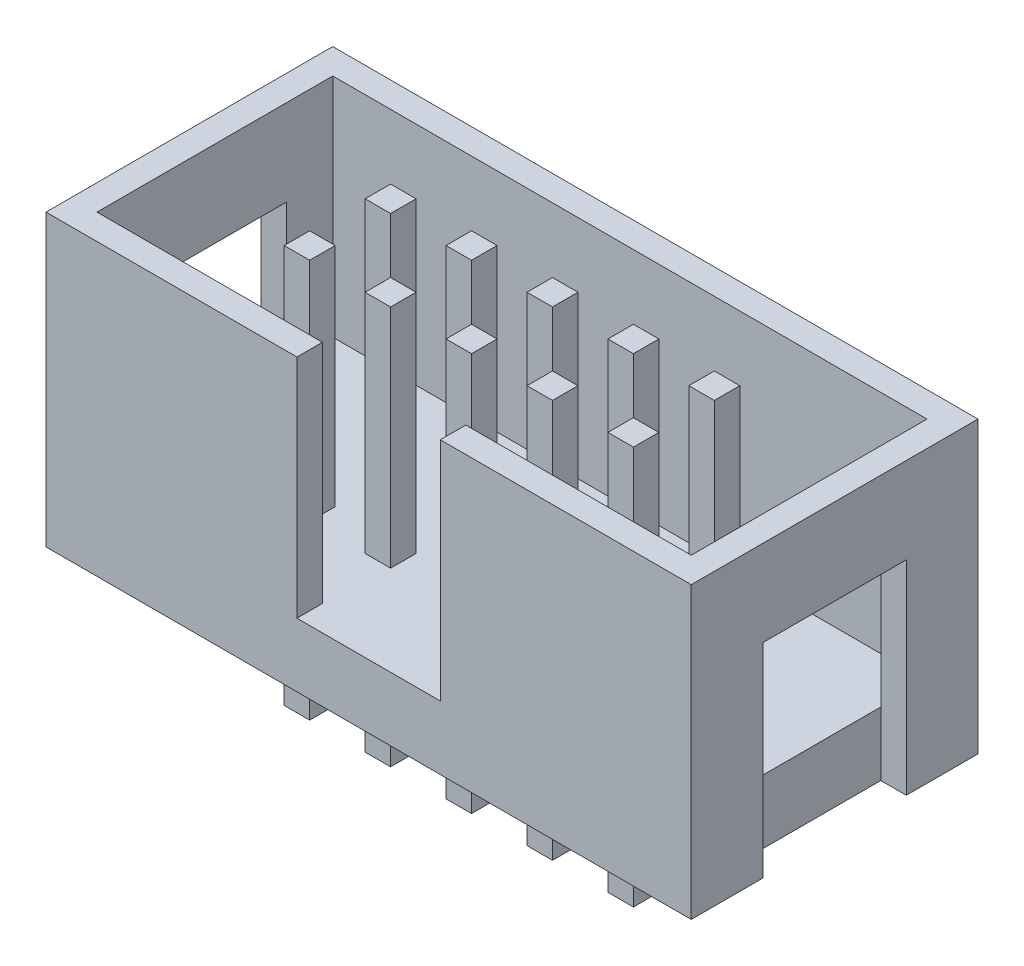
from build123d import *

# Parameters (mm, degrees)
SKETCH1_W           = 20.25
SKETCH1_H           = 9
BOSS_EXTRUDE1_DEPTH = 9.1
SKETCH2_W           = 18.65
SKETCH2_H           = 7.4
CUT_EXTRUDE1_DEPTH  = 7.1
SKETCH2_3_W         = 0.8
SKETCH2_3_H         = 0.8
BOSS_EXTRUDE2_DEPTH = 12.5
SKETCH3_W           = 4.5
SKETCH3_H           = 7.1
CUT_EXTRUDE2_DEPTH  = 2.1
SKETCH5_W           = 4.5
SKETCH5_H           = 6.4
CUT_EXTRUDE3_DEPTH  = 0.8
SKETCH6_W           = 4.5
SKETCH6_H           = 6.4
CUT_EXTRUDE4_DEPTH  = 0.8


with BuildPart() as part:
    # Sketch1 → Boss-Extrude1 (new body)
    with BuildSketch(Plane(origin=(0, 0, 0), x_dir=(1, 0, 0), z_dir=(0, 1, 0))):
        with Locations((-29.615572658, 24.590099186)):
            Rectangle(SKETCH1_W, SKETCH1_H)
    extrude(amount=BOSS_EXTRUDE1_DEPTH)

    # Sketch2 → Cut-Extrude1 (cut)
    with BuildSketch(Plane(origin=(0, 9.1, 0), x_dir=(1, 0, 0), z_dir=(0, 1, 0))):
        with Locations((-29.615572658, 24.590099186)):
            Rectangle(SKETCH2_W, SKETCH2_H)
    extrude(amount=-CUT_EXTRUDE1_DEPTH, mode=Mode.SUBTRACT)

    # Sketch2_3 → Boss-Extrude2 (add)
    with BuildSketch(Plane(origin=(0, 9.1, 0), x_dir=(1, 0, 0), z_dir=(0, 1, 0))):
        with Locations((-32.155572658, 23.320099186)):
            Rectangle(SKETCH2_3_W, SKETCH2_3_H)
        with Locations((-29.615572658, 23.320099186)):
            Rectangle(SKETCH2_3_W, SKETCH2_3_H)
        with Locations((-27.075572658, 23.320099186)):
            Rectangle(SKETCH2_3_W, SKETCH2_3_H)
        with Locations((-24.535572658, 23.320099186)):
            Rectangle(SKETCH2_3_W, SKETCH2_3_H)
        with Locations((-29.615572658, 25.860099186)):
            Rectangle(SKETCH2_3_W, SKETCH2_3_H)
        with Locations((-27.075572658, 25.860099186)):
            Rectangle(SKETCH2_3_W, SKETCH2_3_H)
        with Locations((-24.535572658, 25.860099186)):
            Rectangle(SKETCH2_3_W, SKETCH2_3_H)
        with Locations((-32.155572658, 25.860099186)):
            Rectangle(SKETCH2_3_W, SKETCH2_3_H)
        with Locations((-34.695572658, 23.320099186)):
            Rectangle(SKETCH2_3_W, SKETCH2_3_H)
        with Locations((-34.695572658, 25.860099186)):
            Rectangle(SKETCH2_3_W, SKETCH2_3_H)
    extrude(amount=-BOSS_EXTRUDE2_DEPTH)

    # Sketch3 → Cut-Extrude2 (cut)
    with BuildSketch(Plane.XY.offset(-20.090099186)):
        with Locations((-29.615572658, 5.55)):
            Rectangle(SKETCH3_W, SKETCH3_H)
    extrude(amount=-CUT_EXTRUDE2_DEPTH, mode=Mode.SUBTRACT)

    # Sketch5 → Cut-Extrude3 (cut)
    with BuildSketch(Plane.ZY.offset(39.740572658)):
        with Locations((-24.590099186, 3.2)):
            Rectangle(SKETCH5_W, SKETCH5_H)
    extrude(amount=-CUT_EXTRUDE3_DEPTH, mode=Mode.SUBTRACT)

    # Sketch6 → Cut-Extrude4 (cut)
    with BuildSketch(Plane(origin=(-19.490572658, 0, 0), x_dir=(0, 0, -1), z_dir=(1, 0, 0))):
        with Locations((24.590099186, 3.2)):
            Rectangle(SKETCH6_W, SKETCH6_H)
    extrude(amount=-CUT_EXTRUDE4_DEPTH, mode=Mode.SUBTRACT)


solid = part.part
